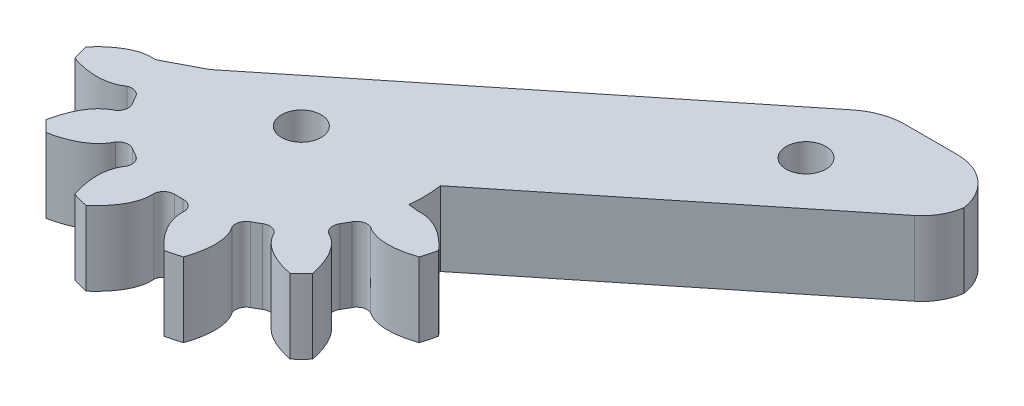
from build123d import *

# Parameters (mm, degrees)
ESBO_O1_R                = 1.6
RESSALTO_EXTRUS_O1_DEPTH = 6


with BuildPart() as part:
    # Esboço1 → Ressalto-extrusão1 (new body)
    with BuildSketch(Plane.XZ.offset(6)):
        with BuildLine():
            Line((24.26036734, -24.5), (28.5, -24.5))
            ThreePointArc((28.5, -24.5), (31.122071197, -23.520718894), (32.460270003, -21.062371319))
            ThreePointArc((32.460270003, -21.062371319), (31.976417823, -19.646228266), (31.005959689, -18.507024557))
            Line((31.005959689, -18.507024557), (9.788591406, -1.452926582))
            ThreePointArc((9.788591406, -1.452926582), (9.894598333, -0.1563368), (9.829606895, 1.142954792))
            Line((9.829606895, 1.142954792), (10.623194285, 1.235230559))
            ThreePointArc((10.623194285, 1.235230559), (10.637816884, 1.237287137), (10.652472585, 1.239092776))
            add(Edge.make_bspline(
                [(10.652472585, 1.239092776), (12.4185109, 1.078975114), (14.239640851, 3.147417918)],
                knots=[0.078549619, 0.078549619, 0.078549619, 0.770539159, 0.770539159, 0.770539159], degree=2, weights=[1, 0.940738559, 1]))
            ThreePointArc((14.239640851, 3.147417918), (14.0864183, 3.774444408), (13.905599677, 4.394076552))
            add(Edge.make_bspline(
                [(13.905599677, 4.394076552), (11.294233474, 5.274835591), (9.84485826, 4.253150471)],
                knots=[5.512646149, 5.512646149, 5.512646149, 6.204635688, 6.204635688, 6.204635688], degree=2, weights=[1, 0.940738559, 1]))
            ThreePointArc((9.84485826, 4.253150471), (9.217248741, 4.230244905), (8.740864349, 4.639483569))
            ThreePointArc((8.740864349, 4.639483569), (8.570043058, 4.947916667), (8.388342806, 5.250068793))
            ThreePointArc((8.388342806, 5.250068793), (8.272123923, 5.86724911), (8.605765484, 6.399322114))
            add(Edge.make_bspline(
                [(8.605765484, 6.399322114), (10.21525836, 7.143675309), (10.758181759, 9.845564299)],
                knots=[0.078549619, 0.078549619, 0.078549619, 0.770539159, 0.770539159, 0.770539159], degree=2, weights=[1, 0.940738559, 1]))
            ThreePointArc((10.758181759, 9.845564299), (10.311973892, 10.311973892), (9.845564299, 10.758181759))
            add(Edge.make_bspline(
                [(9.845564299, 10.758181759), (7.143675309, 10.21525836), (6.399322114, 8.605765484)],
                knots=[2.371053495, 2.371053495, 2.371053495, 3.063043035, 3.063043035, 3.063043035], degree=2, weights=[1, 0.940738559, 1]))
            ThreePointArc((6.399322114, 8.605765484), (5.86724911, 8.272123923), (5.250068793, 8.388342806))
            ThreePointArc((5.250068793, 8.388342806), (4.947916667, 8.570043058), (4.639483569, 8.740864349))
            ThreePointArc((4.639483569, 8.740864349), (4.230244905, 9.217248741), (4.253150471, 9.84485826))
            add(Edge.make_bspline(
                [(4.253150471, 9.84485826), (5.274835591, 11.294233474), (4.394076552, 13.905599677)],
                knots=[0.078549619, 0.078549619, 0.078549619, 0.770539159, 0.770539159, 0.770539159], degree=2, weights=[1, 0.940738559, 1]))
            ThreePointArc((4.394076552, 13.905599677), (3.774444408, 14.0864183), (3.147417918, 14.239640851))
            add(Edge.make_bspline(
                [(3.147417918, 14.239640851), (1.078975114, 12.4185109), (1.239092776, 10.652472585)],
                knots=[2.371053495, 2.371053495, 2.371053495, 3.063043035, 3.063043035, 3.063043035], degree=2, weights=[1, 0.940738559, 1]))
            ThreePointArc((1.239092776, 10.652472585), (0.945124819, 10.097494016), (0.352521544, 9.889552362))
            ThreePointArc((0.352521544, 9.889552362), (0, 9.895833333), (-0.352521544, 9.889552362))
            ThreePointArc((-0.352521544, 9.889552362), (-0.945124819, 10.097494016), (-1.239092776, 10.652472585))
            add(Edge.make_bspline(
                [(-1.239092776, 10.652472585), (-1.078975114, 12.4185109), (-3.147417918, 14.239640851)],
                knots=[0.078549619, 0.078549619, 0.078549619, 0.770539159, 0.770539159, 0.770539159], degree=2, weights=[1, 0.940738559, 1]))
            ThreePointArc((-3.147417918, 14.239640851), (-3.774444408, 14.0864183), (-4.394076552, 13.905599677))
            add(Edge.make_bspline(
                [(-4.394076552, 13.905599677), (-5.274835591, 11.294233474), (-4.253150471, 9.84485826)],
                knots=[2.371053495, 2.371053495, 2.371053495, 3.063043035, 3.063043035, 3.063043035], degree=2, weights=[1, 0.940738559, 1]))
            ThreePointArc((-4.253150471, 9.84485826), (-4.230244905, 9.217248741), (-4.639483569, 8.740864349))
            ThreePointArc((-4.639483569, 8.740864349), (-4.947916667, 8.570043058), (-5.250068793, 8.388342806))
            ThreePointArc((-5.250068793, 8.388342806), (-5.86724911, 8.272123923), (-6.399322114, 8.605765484))
            add(Edge.make_bspline(
                [(-6.399322114, 8.605765484), (-7.143675309, 10.21525836), (-9.845564299, 10.758181759)],
                knots=[0.078549619, 0.078549619, 0.078549619, 0.770539159, 0.770539159, 0.770539159], degree=2, weights=[1, 0.940738559, 1]))
            ThreePointArc((-9.845564299, 10.758181759), (-10.311973892, 10.311973892), (-10.758181759, 9.845564299))
            add(Edge.make_bspline(
                [(-10.758181759, 9.845564299), (-10.21525836, 7.143675309), (-8.605765484, 6.399322114)],
                knots=[2.371053495, 2.371053495, 2.371053495, 3.063043035, 3.063043035, 3.063043035], degree=2, weights=[1, 0.940738559, 1]))
            ThreePointArc((-8.605765484, 6.399322114), (-8.272123923, 5.86724911), (-8.388342806, 5.250068793))
            ThreePointArc((-8.388342806, 5.250068793), (-8.570043058, 4.947916667), (-8.740864349, 4.639483569))
            ThreePointArc((-8.740864349, 4.639483569), (-9.217248741, 4.230244905), (-9.84485826, 4.253150471))
            add(Edge.make_bspline(
                [(-9.84485826, 4.253150471), (-11.294233474, 5.274835591), (-13.905599677, 4.394076552)],
                knots=[3.220142273, 3.220142273, 3.220142273, 3.912131812, 3.912131812, 3.912131812], degree=2, weights=[1, 0.940738559, 1]))
            ThreePointArc((-13.905599677, 4.394076552), (-14.0864183, 3.774444408), (-14.239640851, 3.147417918))
            add(Edge.make_bspline(
                [(-14.239640851, 3.147417918), (-12.4185109, 1.078975114), (-10.652472585, 1.239092776)],
                knots=[2.371053495, 2.371053495, 2.371053495, 3.063043035, 3.063043035, 3.063043035], degree=2, weights=[1, 0.940738559, 1]))
            ThreePointArc((-10.652472585, 1.239092776), (-10.557951639, 1.222896434), (-10.465816504, 1.196294788))
            ThreePointArc((-10.465816504, 1.196294788), (-10.466260875, 1.201681391), (-10.466707243, 1.207067829))
            Line((-10.466707243, 1.207067829), (-7.642065772, -0.272407964))
            Line((-7.642065772, -0.272407964), (21.127917729, -23.397147602))
            ThreePointArc((21.127917729, -23.397147602), (22.599906261, -24.216234622), (24.26036734, -24.5))
        make_face()
        Circle(ESBO_O1_R, mode=Mode.SUBTRACT)
        with Locations((22.598401843, -18.16414524)):
            Circle(ESBO_O1_R, mode=Mode.SUBTRACT)
    extrude(amount=-RESSALTO_EXTRUS_O1_DEPTH)


solid = part.part
